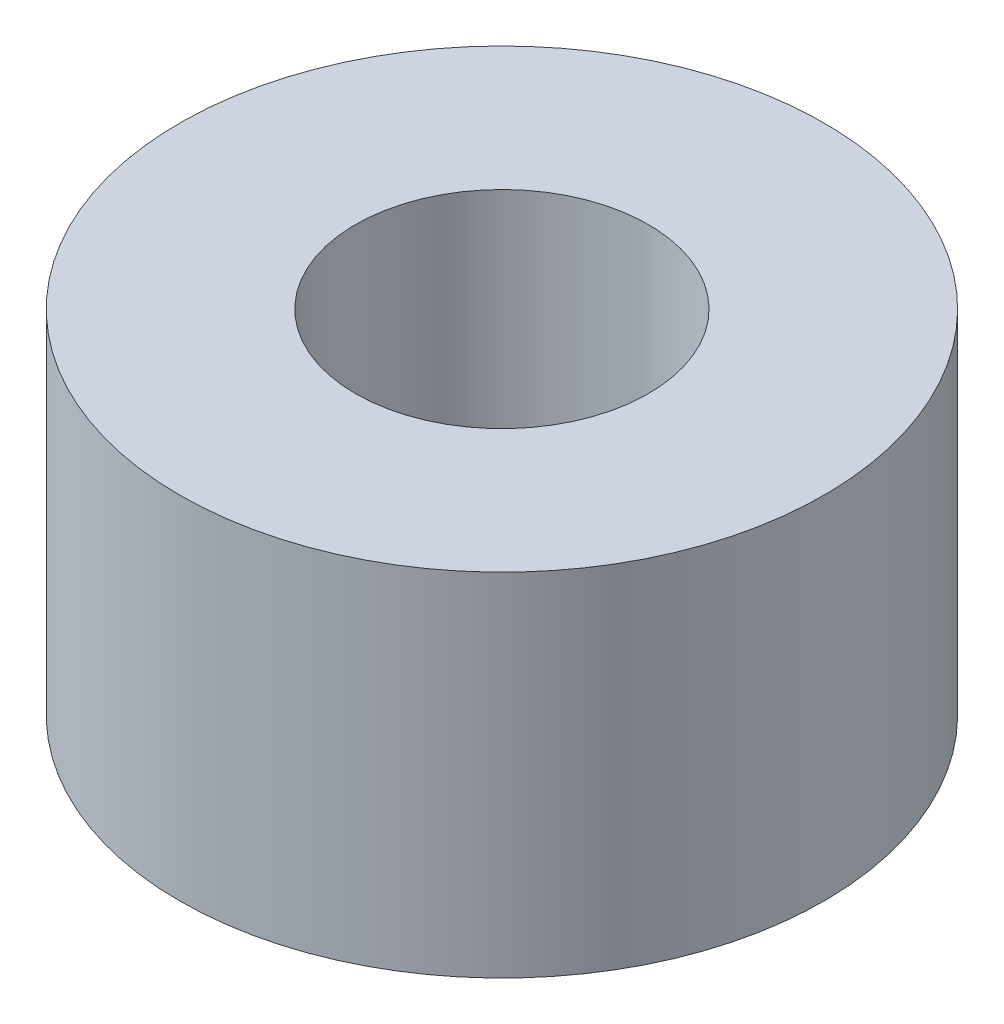
from build123d import *

# Parameters (mm, degrees)
SKETCH1_R           = 5.5
SKETCH1_R_2         = 2.5
BOSS_EXTRUDE1_DEPTH = 6


with BuildPart() as part:
    # Sketch1 → Boss-Extrude1 (new body)
    with BuildSketch(Plane(origin=(0, 0, 0), x_dir=(1, 0, 0), z_dir=(0, 1, 0))):
        Circle(SKETCH1_R)
        Circle(SKETCH1_R_2, mode=Mode.SUBTRACT)
    extrude(amount=BOSS_EXTRUDE1_DEPTH)


solid = part.part
